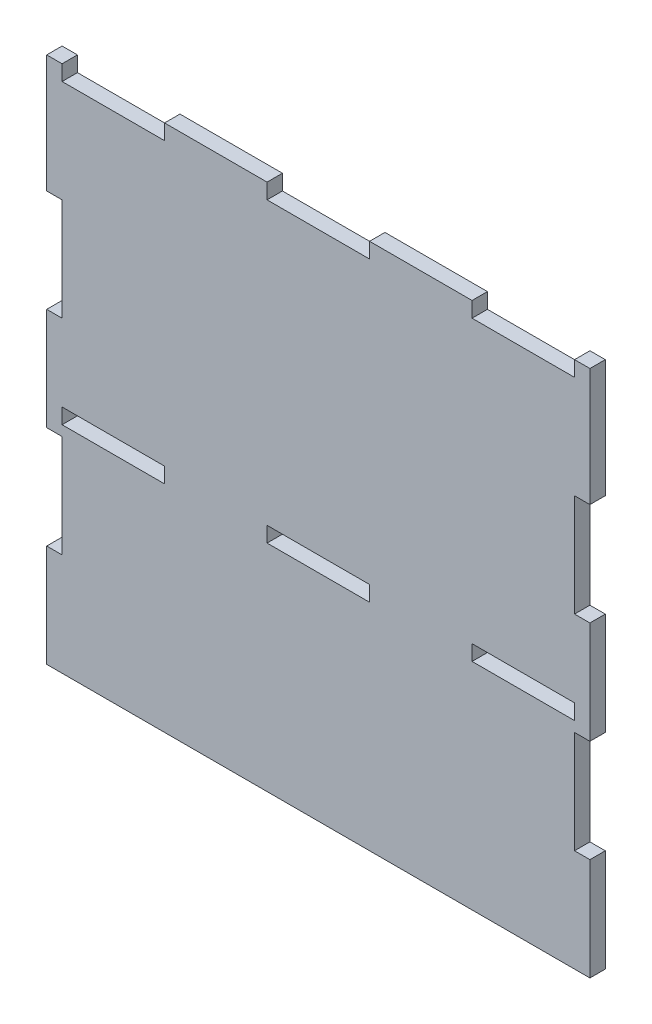
from build123d import *

# Parameters (mm, degrees)
SKETCH1_W           = 100
SKETCH1_H           = 100
BOSS_EXTRUDE1_DEPTH = 3
SKETCH2_W           = 20
SKETCH2_H           = 3
BOSS_EXTRUDE3_DEPTH = 3
SKETCH3_W           = 20
SKETCH3_H           = 3
BOSS_EXTRUDE4_DEPTH = 3
SKETCH5_W           = 3
SKETCH5_H           = 23
SKETCH5_H_2         = 20
BOSS_EXTRUDE5_DEPTH = 3
SKETCH6_W           = 3
SKETCH6_H           = 23
SKETCH6_H_2         = 20
BOSS_EXTRUDE6_DEPTH = 3
SKETCH7_W           = 20
SKETCH7_H           = 3
CUT_EXTRUDE1_DEPTH  = 3


with BuildPart() as part:
    # Sketch1 → Boss-Extrude1 (new body)
    with BuildSketch(Plane.XY):
        with Locations((50, 50)):
            Rectangle(SKETCH1_W, SKETCH1_H)
    extrude(amount=BOSS_EXTRUDE1_DEPTH)

    # Sketch2 → Boss-Extrude3 (add)
    with BuildSketch(Plane(origin=(0, 0, 0), x_dir=(-1, 0, 0), z_dir=(0, 0, -1))):
        with Locations((-30, 101.5)):
            Rectangle(SKETCH2_W, SKETCH2_H)
    extrude(amount=-BOSS_EXTRUDE3_DEPTH)

    # Sketch3 → Boss-Extrude4 (add)
    with BuildSketch(Plane.XY.offset(3)):
        with Locations((70, 101.5)):
            Rectangle(SKETCH3_W, SKETCH3_H)
    extrude(amount=-BOSS_EXTRUDE4_DEPTH)

    # Sketch5 → Boss-Extrude5 (add)
    with BuildSketch(Plane(origin=(0, 0, 0), x_dir=(-1, 0, 0), z_dir=(0, 0, -1))):
        with Locations((-101.5, 91.5)):
            Rectangle(SKETCH5_W, SKETCH5_H)
        with Locations((-101.5, 50)):
            Rectangle(SKETCH5_W, SKETCH5_H_2)
        with Locations((-101.5, 10)):
            Rectangle(SKETCH5_W, SKETCH5_H_2)
    extrude(amount=-BOSS_EXTRUDE5_DEPTH)

    # Sketch6 → Boss-Extrude6 (add)
    with BuildSketch(Plane(origin=(0, 0, 0), x_dir=(-1, 0, 0), z_dir=(0, 0, -1))):
        with Locations((1.5, 91.5)):
            Rectangle(SKETCH6_W, SKETCH6_H)
        with Locations((1.5, 50)):
            Rectangle(SKETCH6_W, SKETCH6_H_2)
        with Locations((1.5, 10)):
            Rectangle(SKETCH6_W, SKETCH6_H_2)
    extrude(amount=-BOSS_EXTRUDE6_DEPTH)

    # Sketch7 → Cut-Extrude1 (cut)
    with BuildSketch(Plane.XY.offset(3)):
        with Locations((10, 43.5)):
            Rectangle(SKETCH7_W, SKETCH7_H)
        with Locations((50, 43.5)):
            Rectangle(SKETCH7_W, SKETCH7_H)
        with Locations((90, 43.5)):
            Rectangle(SKETCH7_W, SKETCH7_H)
    extrude(amount=-CUT_EXTRUDE1_DEPTH, mode=Mode.SUBTRACT)


solid = part.part
